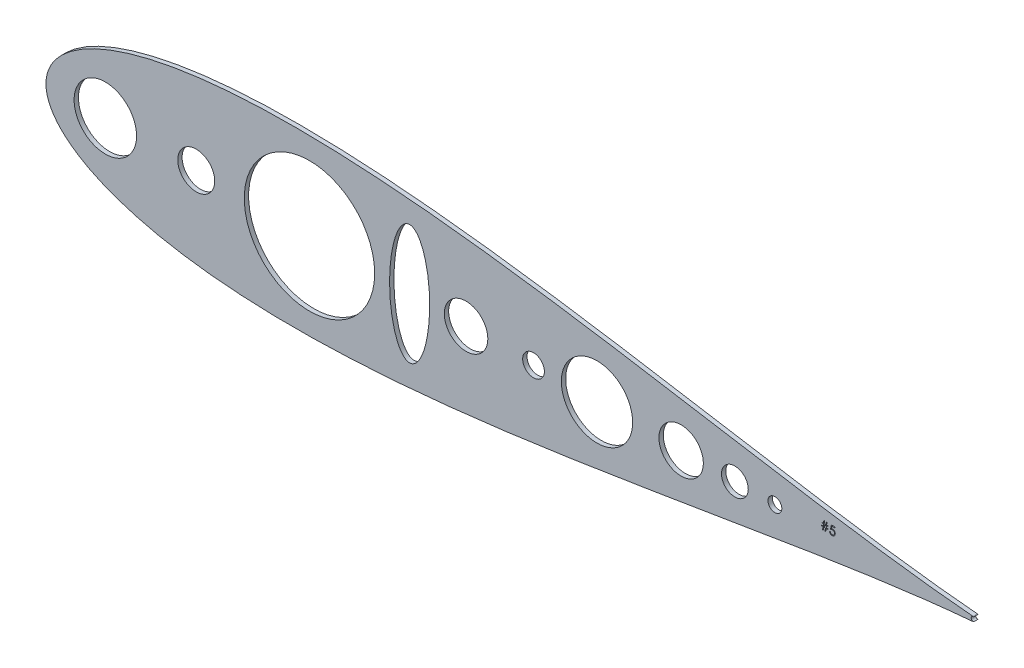
from build123d import *

# Parameters (mm, degrees)
SKETCH2_R           = 18.230878517
SKETCH2_R_2         = 4.037715602
SKETCH2_R_3         = 7.821827667
SKETCH2_R_4         = 12.957792122
SKETCH2_R_5         = 20.813476486
SKETCH2_R_6         = 6.35
SKETCH2_R_7         = 12.7
SKETCH2_R_8         = 38.053042593
SKETCH2_R_9         = 10.795
SKETCH2_RX          = 34.947973864
SKETCH2_RY          = 11.708179647
BOSS_EXTRUDE1_DEPTH = 2.54


with BuildPart() as part:
    # Sketch2 → Boss-Extrude1 (new body)
    with BuildSketch(Plane.XY):
        with BuildLine():
            ThreePointArc((453.717297443, 1.231458475), (452.294205656, 0.000730271), (453.715305569, -1.232297379))
            ThreePointArc((453.715305569, -1.232297379), (453.515715273, -1.298239741), (453.308255093, -1.332076933))
            add(Edge.make_bspline(
                [(453.308255093, 1.332076933), (452.872556363, 1.368309474), (449.589039338, 1.644886078), (443.122554304, 2.242570588), (433.524012572, 3.241071588), (422.881860328, 4.466329207), (411.23610276, 5.925688595), (398.641072349, 7.620635639), (385.151235959, 9.547370327), (370.825009455, 11.695940248), (355.723228961, 14.051060877), (339.9091621, 16.591704023), (323.448162064, 19.291628333), (306.407477633, 22.119707165), (288.856035285, 25.04024426), (270.864323692, 28.013612912), (252.504277787, 30.996731702), (233.849218125, 33.943770696), (214.973811143, 36.806769135), (195.954066175, 39.536486761), (176.86732656, 42.083028562), (157.792288408, 44.396734099), (138.809013672, 46.428891255), (119.998942384, 48.132596427), (101.444884876, 49.463438735), (83.23102017, 50.380330474), (65.442877664, 50.846280174), (48.167308041, 50.828981438), (31.492512484, 50.300992287), (15.508044051, 49.241640326), (0.305067907, 47.635563914), (-14.023494307, 45.47552344), (-27.382095897, 42.760761189), (-39.671916411, 39.500361264), (-50.789057453, 35.713432074), (-60.622614708, 31.433715795), (-69.053171589, 26.717885398), (-75.954779392, 21.661638996), (-81.211222915, 16.430120829), (-84.769919198, 11.299938425), (-86.754347421, 6.671493907), (-87.555697047, 2.958616753), (-87.738211644, 3e-09), (-87.555697047, -2.958616747), (-86.754347421, -6.671493901), (-84.769919198, -11.299938419), (-81.211222915, -16.430120823), (-75.954779392, -21.66163899), (-69.053171589, -26.717885393), (-60.622614708, -31.433715789), (-50.789057453, -35.713432069), (-39.671916411, -39.500361258), (-27.382095897, -42.760761184), (-14.023494307, -45.475523435), (0.305067907, -47.635563908), (15.508044051, -49.241640321), (31.492512484, -50.300992281), (48.167308041, -50.828981432), (65.442877664, -50.846280169), (83.23102017, -50.380330469), (101.444884876, -49.463438729), (119.998942384, -48.132596421), (138.809013672, -46.428891249), (157.792288408, -44.396734094), (176.86732656, -42.083028557), (195.954066175, -39.536486756), (214.973811143, -36.806769129), (233.849218125, -33.94377069), (252.504277787, -30.996731696), (270.864323692, -28.013612907), (288.856035285, -25.040244255), (306.407477633, -22.11970716), (323.448162064, -19.291628327), (339.9091621, -16.591704017), (355.723228961, -14.051060871), (370.825009455, -11.695940243), (385.151235959, -9.547370321), (398.641072349, -7.620635633), (411.23610276, -5.925688589), (422.881860328, -4.466329201), (433.524012572, -3.241071582), (443.122554304, -2.242570583), (449.589039338, -1.644886072), (452.872556363, -1.368309468), (453.308255093, -1.332076933)],
                knots=[0.020157042, 0.020157042, 0.020157042, 0.020157042, 0.021270888, 0.028552555, 0.036780684, 0.045920102, 0.055931764, 0.066772884, 0.07839713, 0.090754827, 0.103793165, 0.117456432, 0.131686226, 0.146421738, 0.161599998, 0.177156133, 0.193023668, 0.209134786, 0.225420633, 0.241811602, 0.258237647, 0.274628557, 0.290914287, 0.307025229, 0.322892517, 0.338448342, 0.353626207, 0.368361232, 0.382590428, 0.396252961, 0.409290412, 0.42164701, 0.433269881, 0.444109249, 0.45411864, 0.463255055, 0.471479114, 0.478755289, 0.485052318, 0.490344026, 0.494609833, 0.497833231, 0.5, 0.502166769, 0.505390167, 0.509655974, 0.514947682, 0.521244711, 0.528520886, 0.536744945, 0.54588136, 0.555890751, 0.566730119, 0.57835299, 0.590709588, 0.603747039, 0.617409572, 0.631638768, 0.646373793, 0.661551658, 0.677107483, 0.692974771, 0.709085713, 0.725371443, 0.741762353, 0.758188398, 0.774579367, 0.790865214, 0.806976332, 0.822843867, 0.838400002, 0.853578262, 0.868313774, 0.882543568, 0.896206835, 0.909245173, 0.92160287, 0.933227116, 0.944068236, 0.954079898, 0.963219316, 0.971447445, 0.978729112, 0.979842958, 0.979842958, 0.979842958, 0.979842958], degree=3))
            ThreePointArc((453.308255093, 1.332076933), (453.516764757, 1.297982033), (453.717297443, 1.231458475))
        make_face()
        with Locations((-53.054342385, 0)):
            Circle(SKETCH2_R, mode=Mode.SUBTRACT)
        with Locations((337.715895367, 0)):
            Circle(SKETCH2_R_2, mode=Mode.SUBTRACT)
        with Locations((314.353922817, 0)):
            Circle(SKETCH2_R_3, mode=Mode.SUBTRACT)
        with Locations((282.998181099, 0)):
            Circle(SKETCH2_R_4, mode=Mode.SUBTRACT)
        with Locations((233.89367684, 0)):
            Circle(SKETCH2_R_5, mode=Mode.SUBTRACT)
        with Locations((196.85, 0)):
            Circle(SKETCH2_R_6, mode=Mode.SUBTRACT)
        with Locations((157.48, 0)):
            Circle(SKETCH2_R_7, mode=Mode.SUBTRACT)
        with Locations((66.0899332, 0)):
            Circle(SKETCH2_R_8, mode=Mode.SUBTRACT)
        Circle(SKETCH2_R_9, mode=Mode.SUBTRACT)
        with Locations(Location((124.538678522, 0), (0, 0, -90))):
            Ellipse(SKETCH2_RX, SKETCH2_RY, mode=Mode.SUBTRACT)
        Polygon((368.589574112, 3.23132385), (368.589574112, 2.905682825), (367.618756801, 2.905682825), (367.35519109, 1.147221288), (366.961368977, 1.147221288), (367.224934688, 2.905682825), (366.185936288, 2.905682825), (365.922370577, 1.147221288), (365.528548464, 1.147221288), (365.792114175, 2.905682825), (364.942394625, 2.905682825), (364.942394625, 3.23132385), (365.840960326, 3.23132385), (366.017010012, 4.403631538), (365.072651037, 4.403631538), (365.072651037, 4.729272563), (366.065856166, 4.729272563), (366.31008694, 6.357477688), (366.702891428, 6.357477688), (366.458660654, 4.729272563), (367.498676679, 4.729272563), (367.742907453, 6.357477688), (368.13571194, 6.357477688), (367.891481166, 4.729272563), (368.719830524, 4.729272563), (368.719830524, 4.403631538), (367.842635012, 4.403631538), (367.667602951, 3.23132385), align=None, mode=Mode.SUBTRACT)
        Polygon((372.757779243, 6.227228397), (372.757779243, 5.706195639), (371.029846555, 5.706195639), (370.756104568, 4.370049812), (370.917907455, 4.412790189), (371.071569306, 4.444336664), (371.217090143, 4.462653975), (371.354469955, 4.468759749), (371.524413856, 4.46163635), (371.687234369, 4.439248526), (371.841913856, 4.402613913), (371.989469955, 4.351732501), (372.128885017, 4.2866043), (372.260159055, 4.206211664), (372.384309693, 4.111572249), (372.501336942, 4.0016684), (372.607170269, 3.880570639), (372.698756806, 3.752349488), (372.777114181, 3.614969676), (372.84020713, 3.470466475), (372.890070907, 3.316804614), (372.924670269, 3.155001727), (372.946040467, 2.985057825), (372.953163856, 2.806972887), (372.949093344, 2.682822249), (372.938917068, 2.560706862), (372.920599756, 2.441644362), (372.895159055, 2.324617114), (372.862594955, 2.210642762), (372.822907455, 2.099721287), (372.775078929, 1.990835063), (372.72114463, 1.883984101), (372.661104568, 1.782221287), (372.594958737, 1.686564236), (372.524742384, 1.597012954), (372.449437897, 1.513567442), (372.368027645, 1.436227693), (372.281529246, 1.364993718), (372.190960334, 1.299865517), (372.094285658, 1.24084308), (371.993540462, 1.187926413), (371.88872475, 1.143150774), (371.780856162, 1.1044809), (371.668917062, 1.072934425), (371.552907449, 1.04851135), (371.432827313, 1.031211664), (371.308676675, 1.020017762), (371.18147315, 1.016964875), (371.029846549, 1.023070639), (370.884325713, 1.042405576), (370.74491065, 1.072934425), (370.611601351, 1.116692438), (370.484397826, 1.172661988), (370.363300075, 1.241860701), (370.247290462, 1.322253337), (370.138404238, 1.415875126), (370.037659049, 1.519673201), (369.948107763, 1.630594676), (369.868732763, 1.748639551), (369.799534049, 1.87482545), (369.741529238, 2.007117114), (369.694718338, 2.147549812), (369.658083725, 2.2951059), (369.631625389, 2.449785387), (370.087522826, 2.449785387), (370.124157449, 2.305282176), (370.170968338, 2.1760434), (370.22897315, 2.060033787), (370.297154238, 1.958270963), (370.377546863, 1.868719676), (370.470151037, 1.788327051), (370.574966738, 1.71607545), (370.691993987, 1.654000126), (370.816144625, 1.603118714), (370.944365776, 1.567501727), (371.074622188, 1.545113913), (371.207931487, 1.537990513), (371.338187889, 1.544096287), (371.463356162, 1.561395963), (371.584453924, 1.589889551), (371.700463537, 1.630594676), (371.811385012, 1.681476088), (371.918235974, 1.745586664), (372.019998788, 1.819873526), (372.1176911, 1.906371925), (372.20622475, 2.00101135), (372.283564499, 2.101756538), (372.3486927, 2.2086075), (372.402626999, 2.320546601), (372.44434975, 2.438591475), (372.473860974, 2.561724488), (372.491161702, 2.690971134), (372.497267476, 2.826315684), (372.492179328, 2.948431061), (372.476914903, 3.064440684), (372.450456576, 3.174344523), (372.413821953, 3.278142609), (372.367011064, 3.376852536), (372.310023878, 3.469456709), (372.24184279, 3.555955109), (372.163485416, 3.636347735), (372.076987026, 3.709616961), (371.982347602, 3.77270991), (371.881602403, 3.825626574), (371.773733815, 3.870402222), (371.658741828, 3.903983948), (371.536626441, 3.928407023), (371.40840529, 3.942653822), (371.272043114, 3.947741961), (371.15399824, 3.943671448), (371.028829976, 3.93145991), (370.898573564, 3.911107348), (370.761190138, 3.88261301), (370.618722189, 3.845978397), (370.469130839, 3.801202749), (370.314451362, 3.748286085), (370.152648475, 3.687228397), (370.673674113, 6.227228397), align=None, mode=Mode.SUBTRACT)
    extrude(amount=BOSS_EXTRUDE1_DEPTH)


solid = part.part
